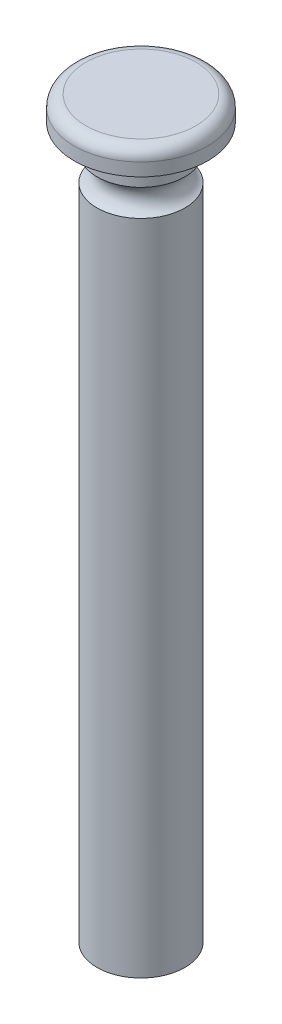
from build123d import *

# Parameters (mm, degrees)
SKETCH2_R      = 9.525
EXTRUDE1_DEPTH = 153.924
SKETCH3_R      = 14.478
EXTRUDE2_DEPTH = 5.334
FILLET1_R      = 2.54


with BuildPart() as part:
    # Sketch2 → Extrude1 (new body)
    with BuildSketch(Plane(origin=(0, 0, 0), x_dir=(1, 0, 0), z_dir=(0, 1, 0))):
        Circle(SKETCH2_R)
    extrude(amount=EXTRUDE1_DEPTH)

    # Sketch3 → Extrude2 (add)
    with BuildSketch(Plane(origin=(0, 153.924, 0), x_dir=(-1, 0, 0), z_dir=(0, 1, 0))):
        Circle(SKETCH3_R)
    extrude(amount=EXTRUDE2_DEPTH)

    # Sketch14 → Cut-Revolve1 (revolve, cut)
    with BuildSketch(Plane.XY):
        with BuildLine():
            Line((9.525, 148.463), (9.525, 142.621))
            ThreePointArc((9.525, 142.621), (7.610493481, 145.542), (9.525, 148.463))
        make_face()
    revolve(axis=Axis((0, 145.542, 0), (0, 1, 0)), mode=Mode.SUBTRACT)

    # Fillet1
    fillet1_edges = [part.edges().sort_by_distance(p)[0] for p in [
        (14.478, 159.258, 0),
    ]]
    fillet(fillet1_edges, radius=FILLET1_R)


solid = part.part
